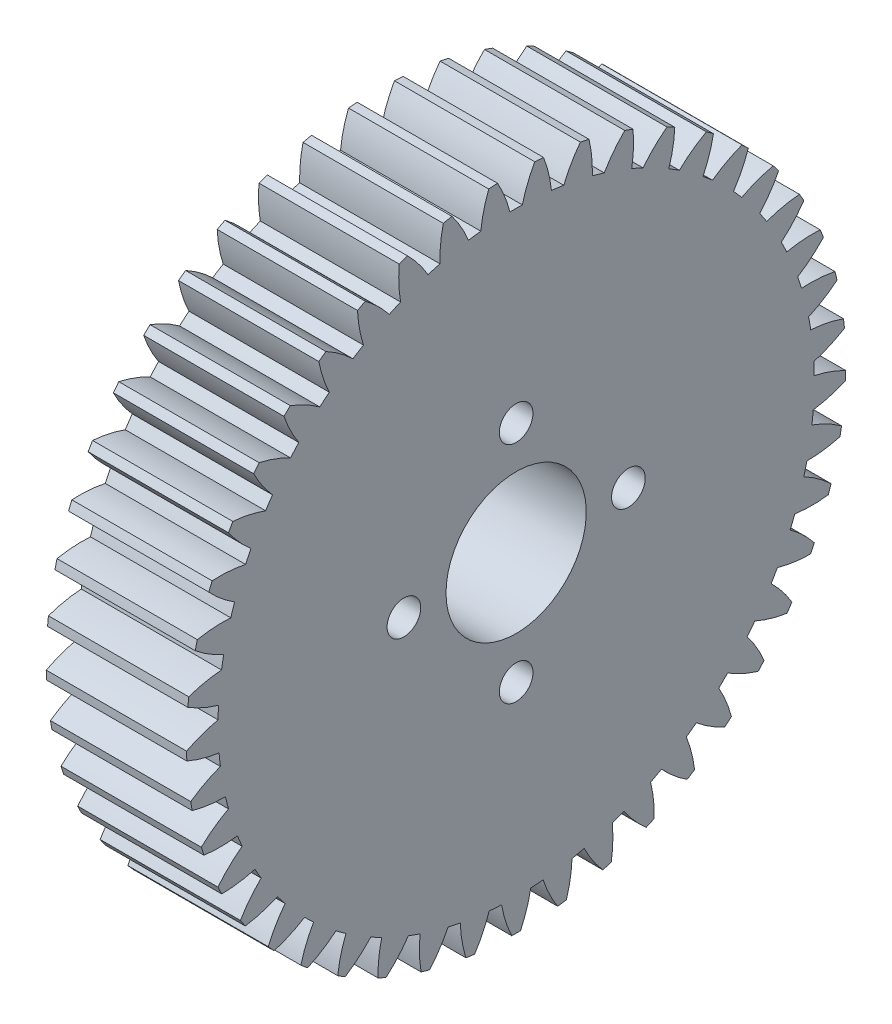
from build123d import *

# Parameters (mm, degrees)
BASPROSKE_W          = 10
BASPROSKE_H          = 23.5
TOOTHCUT_DEPTH       = 35.705907278
TEETHCUTS_COUNT      = 45
TEETHCUTS_ANGLE      = 352
BORSKE_R             = 5
BORE_DEPTH           = 50.0000508
D_GAGEMENT_M21_D     = 2.4
D_GAGEMENT_M21_DEPTH = 10


with BuildPart() as part:
    # BasProSke → Base-Revolve (revolve)
    with BuildSketch(Plane(origin=(0, 0, 0), x_dir=(1, 0, 0), z_dir=(0, 1, 0)), mode=Mode.PRIVATE) as base_revolve_sk:
        with Locations((5, 11.75)):
            Rectangle(BASPROSKE_W, BASPROSKE_H)
    revolve(base_revolve_sk.sketch.rotate(Axis((-10, 0, 0), (1, 0, 0)), 180), axis=Axis((-10, 0, 0), (1, 0, 0)))

    # TooCutSke → ToothCut (cut, through all)
    with BuildSketch(Plane(origin=(0, 0, 0), x_dir=(0, 0, -1), z_dir=(1, 0, 0))):
        with BuildLine():
            ThreePointArc((0.442593582, 21.244390128), (0, 21.249), (-0.442593582, 21.244390128))
            ThreePointArc((-0.442593582, 21.244390128), (-0.816027501, 22.396050003), (-1.340654493, 23.487168639))
            ThreePointArc((-1.340654493, 23.487168639), (0, 23.5254), (1.340654493, 23.487168639))
            ThreePointArc((1.340654493, 23.487168639), (0.816027501, 22.396050003), (0.442593582, 21.244390128))
        make_face()
    toothcut = extrude(amount=TOOTHCUT_DEPTH, mode=Mode.SUBTRACT)

    # TeethCuts: ToothCut ×45 about axis
    teethcuts_axis = Axis((-10, 0, 0), (1, 0, 0))
    for i in range(1, TEETHCUTS_COUNT):
        add(toothcut.rotate(teethcuts_axis, i * TEETHCUTS_ANGLE / (TEETHCUTS_COUNT - 1)), mode=Mode.SUBTRACT)

    # BorSke → Bore (cut, symmetric)
    with BuildSketch(Plane(origin=(0, 0, 0), x_dir=(0, 0, -1), z_dir=(1, 0, 0))):
        with Locations(Location((0, 0, 0), (0, 0, 180))):
            Circle(BORSKE_R)
    extrude(amount=BORE_DEPTH, both=True, mode=Mode.SUBTRACT)

    # Dégagement M21
    with Locations(Plane(origin=(10, 0, 0), x_dir=(0, 0, -1), z_dir=(1, 0, 0))):
        with Locations((0, 8), (8, 0), (0, -8), (-8, 0), (0, 0)):
            Hole(D_GAGEMENT_M21_D / 2, depth=D_GAGEMENT_M21_DEPTH)


solid = part.part
